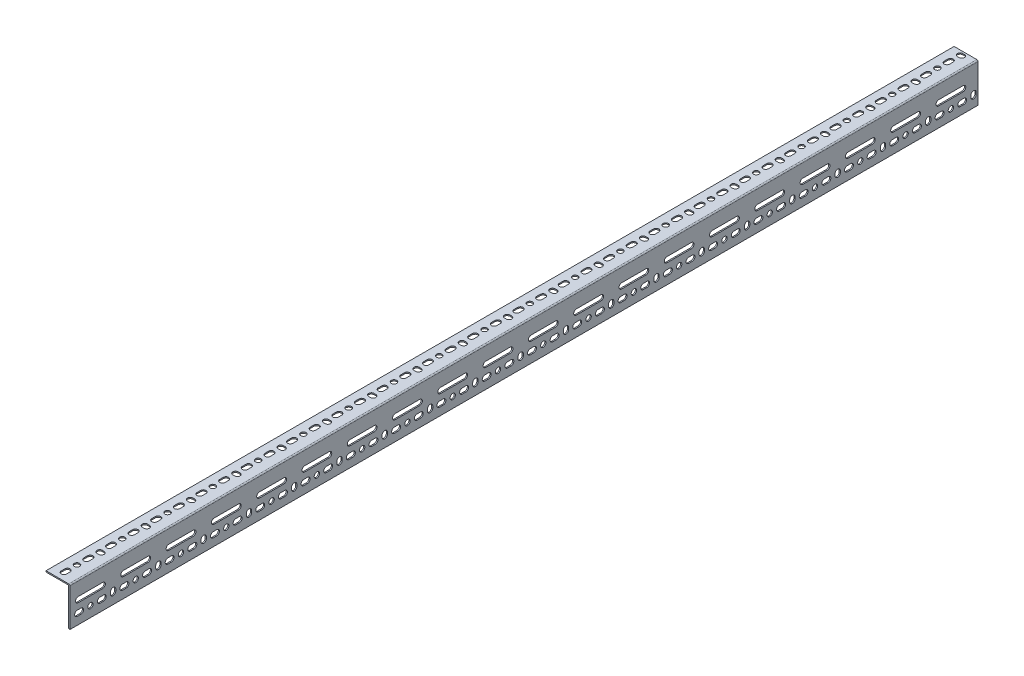
from build123d import *

# Parameters (mm, degrees)
STRUCTURAL_MEMBER1_DEPTH     = 1524
SLOT_1_5_DEPTH               = 1526.933897651
SKETCH13_R                   = 4.5
HOLE_1_5_DEPTH               = 1526.933897651
VERTICAL_SLOT_1_5_DEPTH      = 1526.933897651
SMALL_SLOT_2_5_DEPTH         = 1526.933897651
SKETCH16_R                   = 4.5
HOLE_2_5_DEPTH               = 1526.933897651
VERTICAL_SLOT_2_5_DEPTH      = 1526.933897651
LONG_SLOT_2_5_DEPTH          = 1526.933897651
SHORT_SLOT_PATTERN_1_5_COUNT = 40
SHORT_SLOT_PATTERN_1_5_PITCH = 38
HOLE_PATTERN_COUNT           = 20
HOLE_PATTERN_PITCH           = 76
VERT_SLOT_PATTERN_COUNT      = 20
VERT_SLOT_PATTERN_PITCH      = 76
LONG_SLOT_PATTERN_COUNT      = 20
LONG_SLOT_PATTERN_PITCH      = 76


with BuildPart() as part:
    # Sketch11 → Structural Member1 (new body)
    with BuildSketch(Plane(origin=(0, 0, 0), x_dir=(-1, 0, 0), z_dir=(0, 0, 1))):
        with BuildLine():
            Line((0, 2), (0, 65.5))
            Line((0, 65.5), (1, 65.5))
            ThreePointArc((1, 65.5), (1.707106781, 65.207106781), (2, 64.5))
            Line((2, 64.5), (2, 4))
            ThreePointArc((2, 4), (2.585786438, 2.585786438), (4, 2))
            Line((4, 2), (39.1, 2))
            ThreePointArc((39.1, 2), (39.807106781, 1.707106781), (40.1, 1))
            Line((40.1, 1), (40.1, 0))
            Line((40.1, 0), (2, 0))
            ThreePointArc((2, 0), (0.585786438, 0.585786438), (0, 2))
        make_face()
    extrude(amount=-STRUCTURAL_MEMBER1_DEPTH)

    # Sketch12 → Slot 1.5 (cut, through all)
    with BuildSketch(Plane(origin=(0, 0, 0), x_dir=(1, 0, 0), z_dir=(0, 1, 0))):
        with BuildLine():
            Line((-27.1, 12.5), (-27.1, 18.5))
            ThreePointArc((-27.1, 18.5), (-22.6, 23), (-18.1, 18.5))
            Line((-18.1, 18.5), (-18.1, 12.5))
            ThreePointArc((-18.1, 12.5), (-22.6, 8), (-27.1, 12.5))
        make_face()
    slot_1_5 = extrude(amount=-SLOT_1_5_DEPTH, mode=Mode.SUBTRACT)

    # Sketch13 → Hole 1.5 (cut, through all)
    with BuildSketch(Plane(origin=(0, 0, 0), x_dir=(1, 0, 0), z_dir=(0, 1, 0))):
        with Locations(Location((-22.6, 34.5, 0), (0, 0, 180))):
            Circle(SKETCH13_R)
    hole_1_5 = extrude(amount=-HOLE_1_5_DEPTH, mode=Mode.SUBTRACT)

    # Sketch18 → Vertical Slot 1.5 (cut, through all)
    with BuildSketch(Plane(origin=(0, 0, 0), x_dir=(1, 0, 0), z_dir=(0, 1, 0))):
        with BuildLine():
            Line((-22.6, 77), (-19.6, 77))
            ThreePointArc((-19.6, 77), (-15.1, 72.5), (-19.6, 68))
            Line((-19.6, 68), (-22.6, 68))
            ThreePointArc((-22.6, 68), (-27.1, 72.5), (-22.6, 77))
        make_face()
    vertical_slot_1_5 = extrude(amount=-VERTICAL_SLOT_1_5_DEPTH, mode=Mode.SUBTRACT)

    # Sketch15 → Small Slot 2.5 (cut, through all)
    with BuildSketch(Plane(origin=(0, 0, 0), x_dir=(0, 0, -1), z_dir=(1, 0, 0))):
        with BuildLine():
            Line((12.5, -43.5), (18.5, -43.5))
            ThreePointArc((18.5, -43.5), (23, -48), (18.5, -52.5))
            Line((18.5, -52.5), (12.5, -52.5))
            ThreePointArc((12.5, -52.5), (8, -48), (12.5, -43.5))
        make_face()
    small_slot_2_5 = extrude(amount=-SMALL_SLOT_2_5_DEPTH, mode=Mode.SUBTRACT)

    # Sketch16 → Hole 2.5 (cut, through all)
    with BuildSketch(Plane(origin=(0, 0, 0), x_dir=(0, 0, -1), z_dir=(1, 0, 0))):
        with Locations((34.5, -48)):
            Circle(SKETCH16_R)
    hole_2_5 = extrude(amount=-HOLE_2_5_DEPTH, mode=Mode.SUBTRACT)

    # Sketch17 → Vertical Slot 2.5 (cut, through all)
    with BuildSketch(Plane(origin=(0, 0, 0), x_dir=(0, 0, -1), z_dir=(1, 0, 0))):
        with BuildLine():
            Line((77, -45), (77, -48))
            ThreePointArc((77, -48), (72.5, -52.5), (68, -48))
            Line((68, -48), (68, -45))
            ThreePointArc((68, -45), (72.5, -40.5), (77, -45))
        make_face()
    vertical_slot_2_5 = extrude(amount=-VERTICAL_SLOT_2_5_DEPTH, mode=Mode.SUBTRACT)

    # Sketch14 → Long Slot 2.5 (cut, through all)
    with BuildSketch(Plane(origin=(0, 0, 0), x_dir=(0, 0, -1), z_dir=(1, 0, 0))):
        with BuildLine():
            Line((14, -24.45), (55, -24.45))
            ThreePointArc((55, -24.45), (59.5, -28.95), (55, -33.45))
            Line((55, -33.45), (14, -33.45))
            ThreePointArc((14, -33.45), (9.5, -28.95), (14, -24.45))
        make_face()
    long_slot_2_5 = extrude(amount=-LONG_SLOT_2_5_DEPTH, mode=Mode.SUBTRACT)

    # Short Slot pattern 1.5: Slot 1.5, Small Slot 2.5 ×40
    with Locations(*[(0, 0, -i * SHORT_SLOT_PATTERN_1_5_PITCH) for i in range(1, SHORT_SLOT_PATTERN_1_5_COUNT)]):
        add(slot_1_5, mode=Mode.SUBTRACT)
        add(small_slot_2_5, mode=Mode.SUBTRACT)

    # Hole pattern: Hole 1.5, Hole 2.5 ×20
    with Locations(*[(0, 0, -i * HOLE_PATTERN_PITCH) for i in range(1, HOLE_PATTERN_COUNT)]):
        add(hole_1_5, mode=Mode.SUBTRACT)
        add(hole_2_5, mode=Mode.SUBTRACT)

    # Vert Slot Pattern: Vertical Slot 1.5, Vertical Slot 2.5 ×20
    with Locations(*[(0, 0, -i * VERT_SLOT_PATTERN_PITCH) for i in range(1, VERT_SLOT_PATTERN_COUNT)]):
        add(vertical_slot_1_5, mode=Mode.SUBTRACT)
        add(vertical_slot_2_5, mode=Mode.SUBTRACT)

    # Long Slot pattern: Long Slot 2.5 ×20
    with Locations(*[(0, 0, -i * LONG_SLOT_PATTERN_PITCH) for i in range(1, LONG_SLOT_PATTERN_COUNT)]):
        add(long_slot_2_5, mode=Mode.SUBTRACT)


solid = part.part
